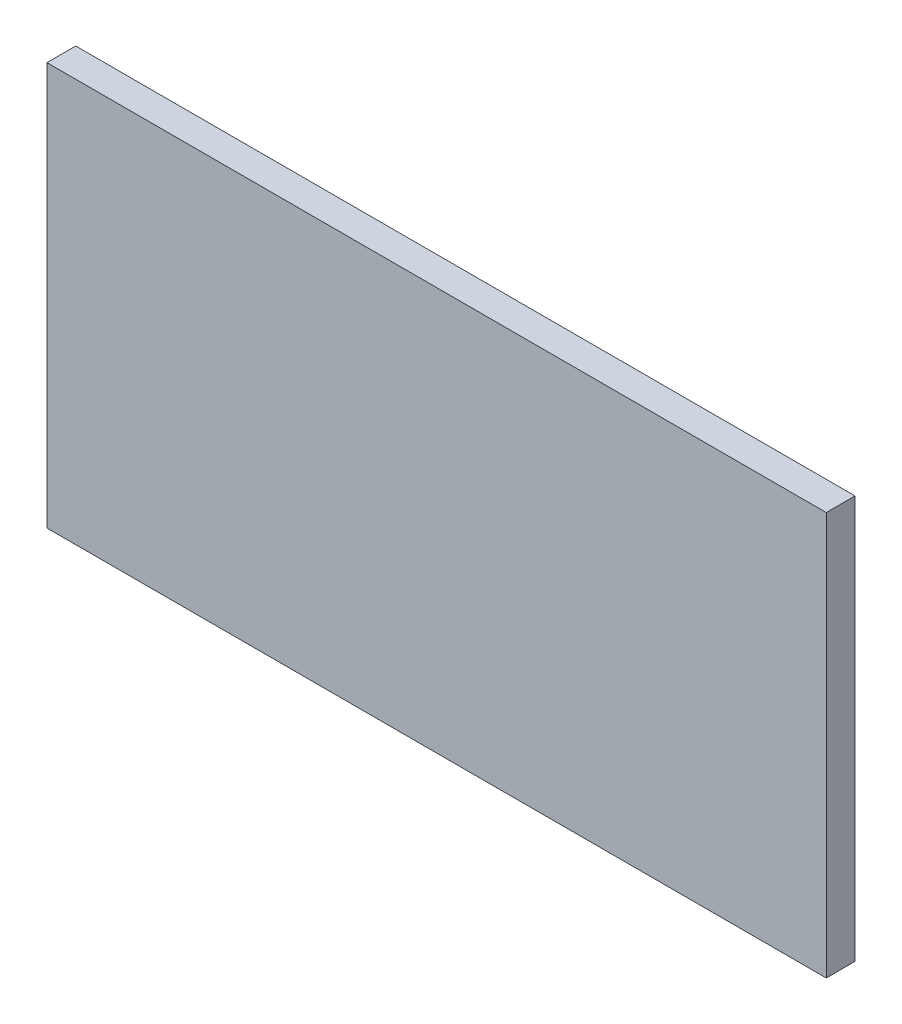
from build123d import *

# Parameters (mm, degrees)
SKETCH1_W           = 40.6
SKETCH1_H           = 21
BOSS_EXTRUDE1_DEPTH = 1.5
SKETCH2_W           = 3.76
SKETCH2_H           = 3
BOSS_EXTRUDE3_DEPTH = 1.1
SKETCH3_R           = 0.25
CUT_EXTRUDE1_DEPTH  = 0.5
FILLET3_R           = 0.5
SKETCH4_R           = 0.65
BOSS_EXTRUDE4_DEPTH = 0.25


with BuildPart() as part:
    # Sketch1 → Boss-Extrude1 (new body)
    with BuildSketch(Plane.XY):
        with Locations((20.3, 10.5)):
            Rectangle(SKETCH1_W, SKETCH1_H)
    extrude(amount=BOSS_EXTRUDE1_DEPTH)

    # Sketch2 → Boss-Extrude3 (add)
    with BuildSketch(Plane(origin=(0, 0, 0), x_dir=(-1, 0, 0), z_dir=(0, 0, -1))):
        with Locations((-8.38, 13.31)):
            Rectangle(SKETCH2_W, SKETCH2_H)
    extrude(amount=BOSS_EXTRUDE3_DEPTH)

    # Sketch3 → Cut-Extrude1 (cut)
    with BuildSketch(Plane(origin=(0, 0, -1.1), x_dir=(-1, 0, 0), z_dir=(0, 0, -1))):
        with Locations((-9.08, 13.31)):
            Circle(SKETCH3_R)
    extrude(amount=-CUT_EXTRUDE1_DEPTH, mode=Mode.SUBTRACT)

    # Fillet3
    fillet3_edges = [part.edges().sort_by_distance(p)[0] for p in [
        (6.5, 13.31, -1.1),
        (8.38, 14.81, -1.1),
        (10.26, 13.31, -1.1),
        (8.38, 11.81, -1.1),
    ]]
    fillet(fillet3_edges, radius=FILLET3_R)

    # Sketch4 → Boss-Extrude4 (add)
    with BuildSketch(Plane(origin=(0, 0, 0), x_dir=(-1, 0, 0), z_dir=(0, 0, -1))):
        with Locations((-18.925, 3.72)):
            Circle(SKETCH4_R)
        with Locations((-20.675, 3.72)):
            Circle(SKETCH4_R)
        with Locations((-20.675, 5.47)):
            Circle(SKETCH4_R)
        with Locations((-20.675, 7.22)):
            Circle(SKETCH4_R)
        with Locations((-18.925, 5.47)):
            Circle(SKETCH4_R)
        with Locations((-18.925, 7.22)):
            Circle(SKETCH4_R)
    extrude(amount=BOSS_EXTRUDE4_DEPTH)


solid = part.part
